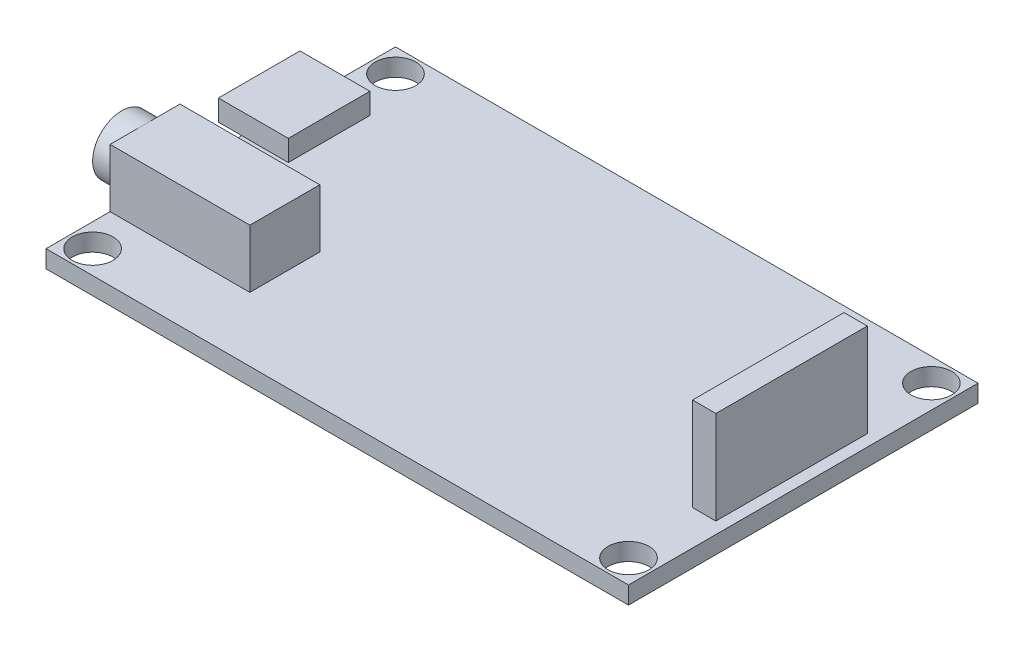
from build123d import *

# Parameters (mm, degrees)
SKETCH1_W           = 50
SKETCH1_H           = 30
BOSS_EXTRUDE1_DEPTH = 1.5
SKETCH2_R           = 1.75
CUT_EXTRUDE1_DEPTH  = 2.5
SKETCH3_W           = 2
SKETCH3_H           = 13
BOSS_EXTRUDE2_DEPTH = 8
SKETCH4_W           = 12
SKETCH4_H           = 6
BOSS_EXTRUDE3_DEPTH = 5
SKETCH5_R           = 2.5
BOSS_EXTRUDE4_DEPTH = 2
SKETCH6_W           = 6
SKETCH6_H           = 7
BOSS_EXTRUDE5_DEPTH = 1.8


with BuildPart() as part:
    # Sketch1 → Boss-Extrude1 (new body)
    with BuildSketch(Plane(origin=(0, 0, 0), x_dir=(1, 0, 0), z_dir=(0, 1, 0))):
        with Locations((25, -15)):
            Rectangle(SKETCH1_W, SKETCH1_H)
    extrude(amount=BOSS_EXTRUDE1_DEPTH)

    # Sketch2 → Cut-Extrude1 (cut, through all)
    with BuildSketch(Plane(origin=(0, 1.5, 0), x_dir=(1, 0, 0), z_dir=(0, 1, 0))):
        with Locations((48, -28)):
            Circle(SKETCH2_R)
        with Locations((48, -2)):
            Circle(SKETCH2_R)
        with Locations((2, -2)):
            Circle(SKETCH2_R)
        with Locations((2, -28)):
            Circle(SKETCH2_R)
    extrude(amount=-CUT_EXTRUDE1_DEPTH, mode=Mode.SUBTRACT)

    # Sketch3 → Boss-Extrude2 (add)
    with BuildSketch(Plane(origin=(0, 1.5, 0), x_dir=(1, 0, 0), z_dir=(0, 1, 0))):
        with Locations((48, -15)):
            Rectangle(SKETCH3_W, SKETCH3_H)
    extrude(amount=BOSS_EXTRUDE2_DEPTH)

    # Sketch4 → Boss-Extrude3 (add)
    with BuildSketch(Plane(origin=(0, 1.5, 0), x_dir=(1, 0, 0), z_dir=(0, 1, 0))):
        with Locations((6, -21.5)):
            Rectangle(SKETCH4_W, SKETCH4_H)
    extrude(amount=BOSS_EXTRUDE3_DEPTH)

    # Sketch5 → Boss-Extrude4 (add)
    with BuildSketch(Plane.ZY):
        with Locations((21.5, 4)):
            Circle(SKETCH5_R)
    extrude(amount=BOSS_EXTRUDE4_DEPTH)

    # Sketch6 → Boss-Extrude5 (add)
    with BuildSketch(Plane(origin=(0, 1.5, 0), x_dir=(1, 0, 0), z_dir=(0, 1, 0))):
        with Locations((1, -9.7)):
            Rectangle(SKETCH6_W, SKETCH6_H)
    extrude(amount=BOSS_EXTRUDE5_DEPTH)


solid = part.part
